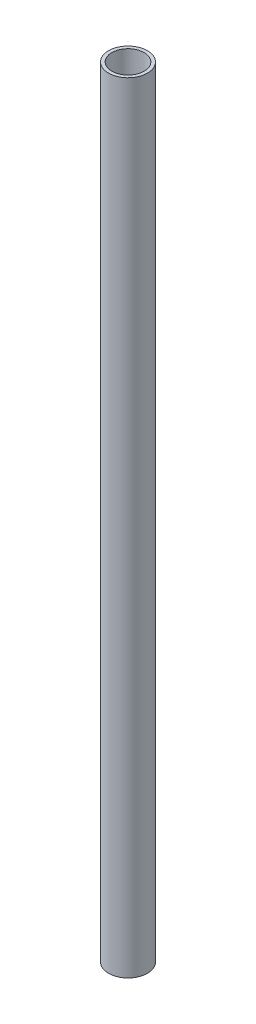
from build123d import *

# Parameters (mm, degrees)
SKETCH1_R           = 21.082
SKETCH1_R_2         = 17.526
BOSS_EXTRUDE1_DEPTH = 844.55


with BuildPart() as part:
    # Sketch1 → Boss-Extrude1 (new body)
    with BuildSketch(Plane(origin=(0, 0, 0), x_dir=(1, 0, 0), z_dir=(0, 1, 0))):
        Circle(SKETCH1_R)
        Circle(SKETCH1_R_2, mode=Mode.SUBTRACT)
    extrude(amount=BOSS_EXTRUDE1_DEPTH)


solid = part.part
